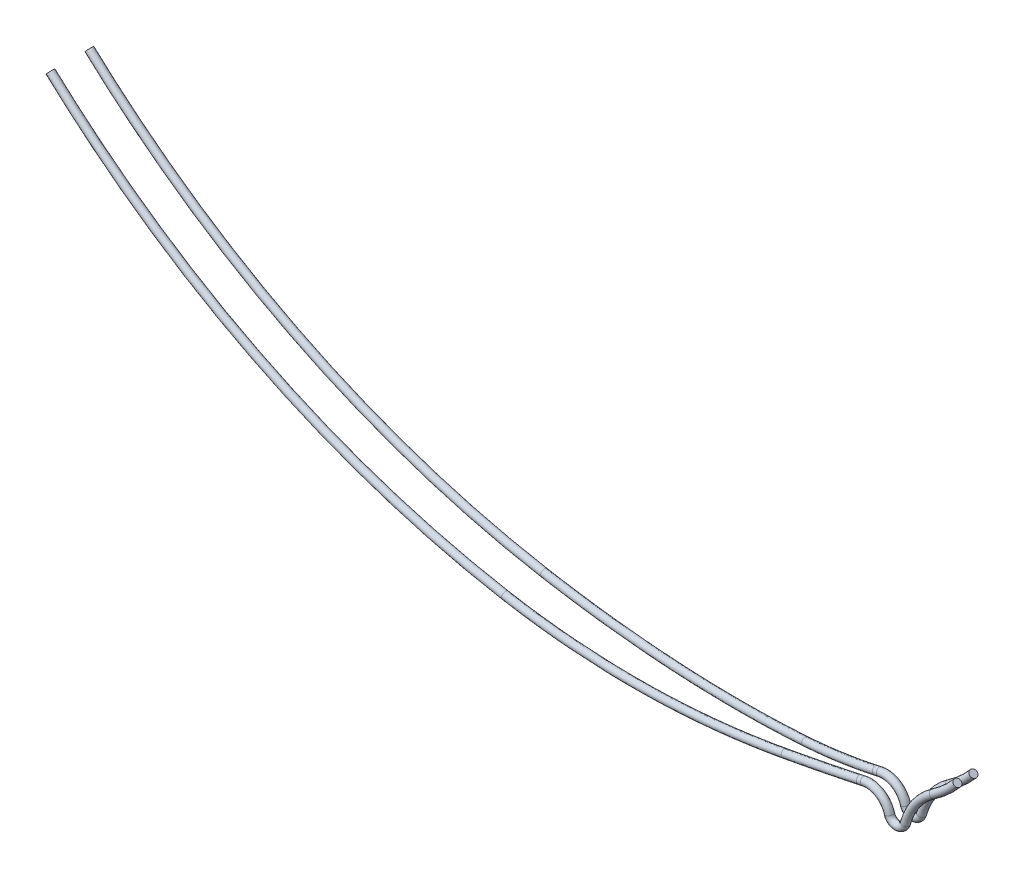
from build123d import *

# Parameters (mm, degrees)
SKETCH_4_R = 0.75
SKETCH_6_R = 0.75


with BuildPart() as part:
    # Sweep 1: sweep along a curve in space
    with BuildLine() as sweep_1_path:
        ThreePointArc((184.033577432, 19.216911575, 1.65), (181.724037621, 16.854720383, 1.65), (179.12628543, 14.813739023, 1.65))
        ThreePointArc((179.12628543, 14.813739023, 1.65), (175.53560253, 11.290348805, 1.65), (173.374033054, 6.747783482, 1.65))
        ThreePointArc((173.374033054, 6.747783482, 1.65), (171.709876944, 5.490587783, 1.65), (170.066172058, 6.774406631, 1.65))
        ThreePointArc((170.066172058, 6.774406631, 1.65), (168.10975149, 9.424250841, 1.65), (164.862426727, 9.97573761, 1.65))
        ThreePointArc((164.862426727, 9.97573761, 1.65), (164.448104982, 9.885727016, 1.65), (164.033577432, 9.79666903, 1.65))
        add(Edge.make_bspline(
            [(164.033577432, 9.79666903, 1.65), (159.063499428, 8.734861186, 1.65), (154.063346826, 7.881056098, 1.814088577), (149.033577432, 7.233949811, 2.149326031)],
            knots=[0, 0, 0, 0, 1, 1, 1, 1], degree=3))
        add(Edge.make_bspline(
            [(149.033577432, 7.233949811, 2.149326031), (139.745065114, 6.038933848, 2.768411517), (130.468085517, 5.560304975, 3.230939381), (111.936293691, 5.991899797, 3.846740517), (102.681480142, 6.902086701, 4), (93.438419589, 8.53338772, 4)],
            knots=[0, 0, 0, 0, 0.5, 0.5, 1, 1, 1, 1], degree=3))
        ThreePointArc((93.438419589, 8.53338772, 4), (43.364619073, 25.021040584, 4), (0, 55, 4))
    # Sketch 4 → Sweep 1 (sweep)
    with BuildSketch(Plane(origin=(0, 55, 4), x_dir=(0, 0, 1), z_dir=(-0.7328637073083618, 0.6803754746536974, 0))):
        Circle(SKETCH_4_R)
    sweep(path=sweep_1_path.line)


with BuildPart() as body_2:
    # Sweep 2: sweep along a curve in space
    with BuildLine() as sweep_2_path:
        ThreePointArc((184.033577432, 19.216911575, -1.65), (181.724037621, 16.854720383, -1.65), (179.12628543, 14.813739023, -1.65))
        ThreePointArc((179.12628543, 14.813739023, -1.65), (175.53560253, 11.290348805, -1.65), (173.374033054, 6.747783482, -1.65))
        ThreePointArc((173.374033054, 6.747783482, -1.65), (171.709876944, 5.490587783, -1.65), (170.066172058, 6.774406631, -1.65))
        ThreePointArc((170.066172058, 6.774406631, -1.65), (168.10975149, 9.424250841, -1.65), (164.862426727, 9.97573761, -1.65))
        ThreePointArc((164.862426727, 9.97573761, -1.65), (164.448104982, 9.885727016, -1.65), (164.033577432, 9.79666903, -1.65))
        add(Edge.make_bspline(
            [(164.033577432, 9.79666903, -1.65), (159.063499428, 8.734861186, -1.65), (154.063346826, 7.881056098, -1.814088577), (149.033577432, 7.233949811, -2.149326031)],
            knots=[0, 0, 0, 0, 1, 1, 1, 1], degree=3))
        add(Edge.make_bspline(
            [(149.033577432, 7.233949811, -2.149326031), (139.745065114, 6.038933848, -2.768411517), (130.468085517, 5.560304975, -3.230939381), (111.936293691, 5.991899797, -3.846740517), (102.681480142, 6.902086701, -4), (93.438419589, 8.53338772, -4)],
            knots=[0, 0, 0, 0, 0.5, 0.5, 1, 1, 1, 1], degree=3))
        ThreePointArc((93.438419589, 8.53338772, -4), (43.364619073, 25.021040584, -4), (0, 55, -4))
    # Sketch 6 → Sweep 2 (sweep)
    with BuildSketch(Plane(origin=(0, 55, 4), x_dir=(0, 0, 1), z_dir=(-0.7328637073083618, 0.6803754746536974, 0))):
        with Locations((-8, 0)):
            Circle(SKETCH_6_R)
    sweep(path=sweep_2_path.line)


solid = Compound([part.part, body_2.part])
